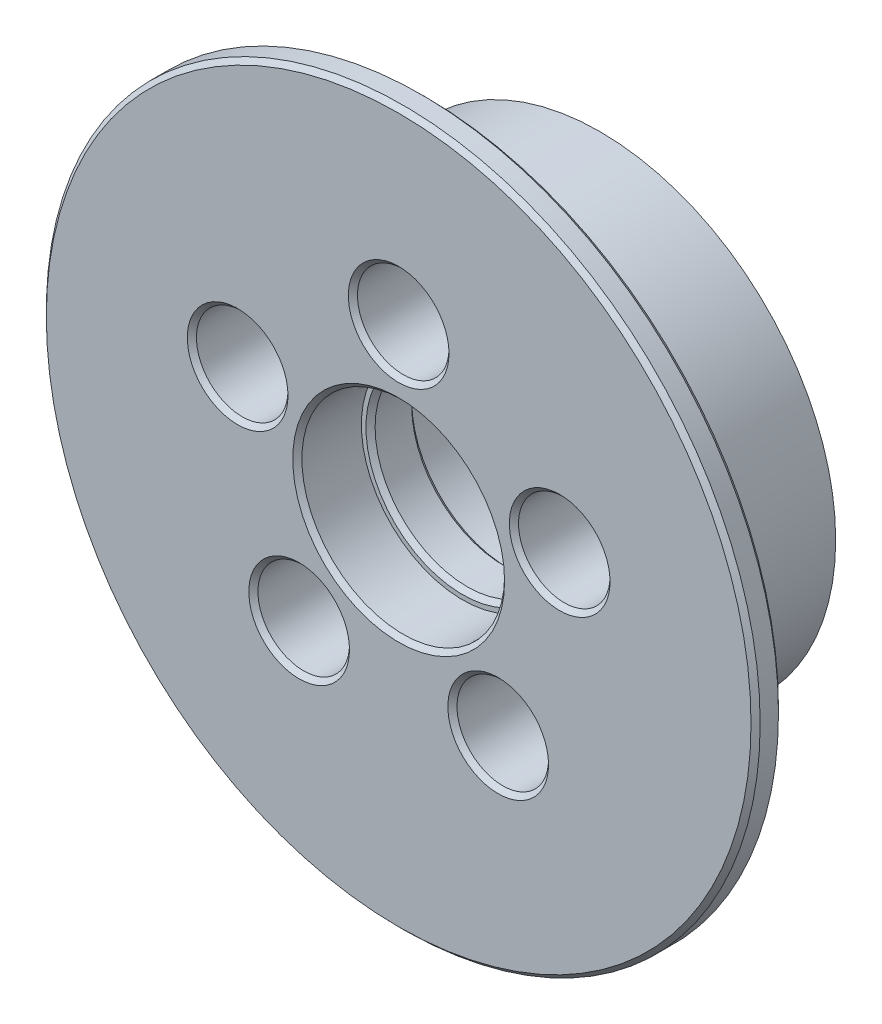
from build123d import *

# Parameters (mm, degrees)
SKETCH1_R           = 25.75
BOSS_EXTRUDE1_DEPTH = 19
SKETCH2_R           = 39
BOSS_EXTRUDE2_DEPTH = 3
SKETCH3_R           = 5
CUT_EXTRUDE1_DEPTH  = 23
SKETCH4_R           = 10.075
CUT_EXTRUDE2_DEPTH  = 23
SKETCH5_R           = 11.075
CUT_EXTRUDE3_DEPTH  = 10
SKETCH6_R           = 11.075
CUT_EXTRUDE4_DEPTH  = 7
CHAMFER1_SIZE       = 0.5
FILLET1_R           = 1


with BuildPart() as part:
    # Sketch1 → Boss-Extrude1 (new body)
    with BuildSketch(Plane.XY):
        Circle(SKETCH1_R)
    extrude(amount=BOSS_EXTRUDE1_DEPTH)

    # Sketch2 → Boss-Extrude2 (add)
    with BuildSketch(Plane.XY.offset(19)):
        Circle(SKETCH2_R)
    extrude(amount=BOSS_EXTRUDE2_DEPTH)

    # Sketch3 → Cut-Extrude1 (cut, through all)
    with BuildSketch(Plane(origin=(0, 0, 0), x_dir=(-1, 0, 0), z_dir=(0, 0, -1))):
        with Locations((0, 18.5)):
            Circle(SKETCH3_R)
        with Locations((17.594545551, 5.716814396)):
            Circle(SKETCH3_R)
        with Locations((10.874027167, -14.966814396)):
            Circle(SKETCH3_R)
        with Locations((-10.874027167, -14.966814396)):
            Circle(SKETCH3_R)
        with Locations((-17.594545551, 5.716814396)):
            Circle(SKETCH3_R)
    extrude(amount=-CUT_EXTRUDE1_DEPTH, mode=Mode.SUBTRACT)

    # Sketch4 → Cut-Extrude2 (cut, through all)
    with BuildSketch(Plane(origin=(0, 0, 0), x_dir=(-1, 0, 0), z_dir=(0, 0, -1))):
        Circle(SKETCH4_R)
    extrude(amount=-CUT_EXTRUDE2_DEPTH, mode=Mode.SUBTRACT)

    # Sketch5 → Cut-Extrude3 (cut)
    with BuildSketch(Plane(origin=(0, 0, 0), x_dir=(-1, 0, 0), z_dir=(0, 0, -1))):
        Circle(SKETCH5_R)
    extrude(amount=-CUT_EXTRUDE3_DEPTH, mode=Mode.SUBTRACT)

    # Sketch6 → Cut-Extrude4 (cut)
    with BuildSketch(Plane.XY.offset(22)):
        Circle(SKETCH6_R)
    extrude(amount=-CUT_EXTRUDE4_DEPTH, mode=Mode.SUBTRACT)

    # Chamfer1
    chamfer1_edges = [part.edges().sort_by_distance(p)[0] for p in [
        (5, 18.5, 22),
        (-12.594545551, 5.716814396, 22),
        (-5.874027167, -14.966814396, 22),
        (15.874027167, -14.966814396, 22),
        (22.594545551, 5.716814396, 22),
        (11.075, 0, 0),
        (10.075, 0, 10),
        (-11.075, 0, 22),
        (10.075, 0, 15),
        (-39, 0, 19),
        (-39, 0, 22),
    ]]
    chamfer(chamfer1_edges, length=CHAMFER1_SIZE)

    # Fillet1
    fillet1_edges = [part.edges().sort_by_distance(p)[0] for p in [
        (5, 18.5, 0),
        (-12.594545551, 5.716814396, 0),
        (-5.874027167, -14.966814396, 0),
        (15.874027167, -14.966814396, 0),
        (22.594545551, 5.716814396, 0),
    ]]
    fillet(fillet1_edges, radius=FILLET1_R)


solid = part.part
